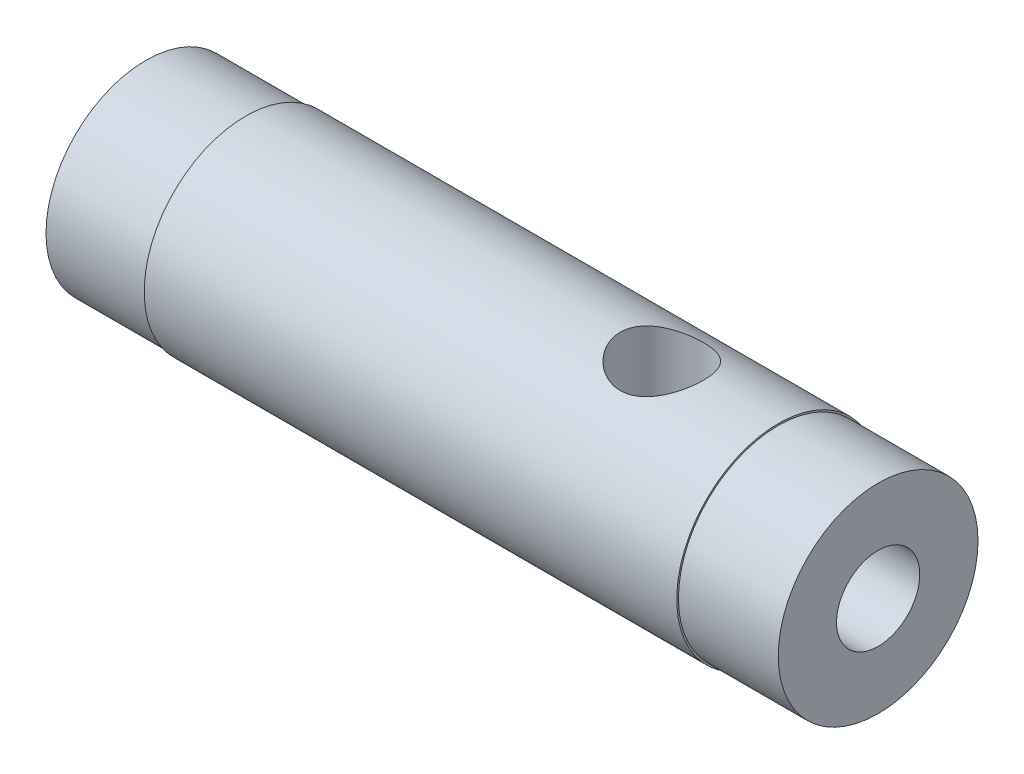
from build123d import *

# Parameters (mm, degrees)
SKIZZE2_R                       = 1
SCHNITT_LINEAR_AUSTRAGEN1_DEPTH = 10
SKIZZE2_3_R                     = 1.25
SKIZZE2_3_R_2                   = 1
SCHNITT_LINEAR_AUSTRAGEN2_DEPTH = 2
SKIZZE3_R                       = 1.25
SCHNITT_LINEAR_AUSTRAGEN3_DEPTH = 12.815455979


with BuildPart() as part:
    # Skizze1 → Rotation1 (revolve)
    with BuildSketch(Plane.XY):
        Polygon((-11, 3), (-8, 3), (-8, 3.05), (8, 3.05), (8, 3), (11, 3), (11, 0), (-11, 0), align=None)
    revolve(axis=Axis((-97.111770595, 0, 0), (-1, 0, 0)))

    # Skizze2 → Schnitt-Linear austragen1 (cut)
    with BuildSketch(Plane(origin=(11, 0, 0), x_dir=(0, 0, -1), z_dir=(1, 0, 0))):
        Circle(SKIZZE2_R)
    extrude(amount=-SCHNITT_LINEAR_AUSTRAGEN1_DEPTH, mode=Mode.SUBTRACT)

    # Skizze2_3 → Schnitt-Linear austragen2 (cut)
    with BuildSketch(Plane(origin=(11, 0, 0), x_dir=(0, 0, -1), z_dir=(1, 0, 0))):
        Circle(SKIZZE2_3_R)
        Circle(SKIZZE2_3_R_2, mode=Mode.SUBTRACT)
    extrude(amount=-SCHNITT_LINEAR_AUSTRAGEN2_DEPTH, mode=Mode.SUBTRACT)

    # Skizze3 → Schnitt-Linear austragen3 (cut, through all)
    with BuildSketch(Plane(origin=(0, 0, 0), x_dir=(1, 0, 0), z_dir=(0, 1, 0))):
        with Locations((4.5, 0)):
            Circle(SKIZZE3_R)
    extrude(amount=SCHNITT_LINEAR_AUSTRAGEN3_DEPTH, mode=Mode.SUBTRACT)


solid = part.part
